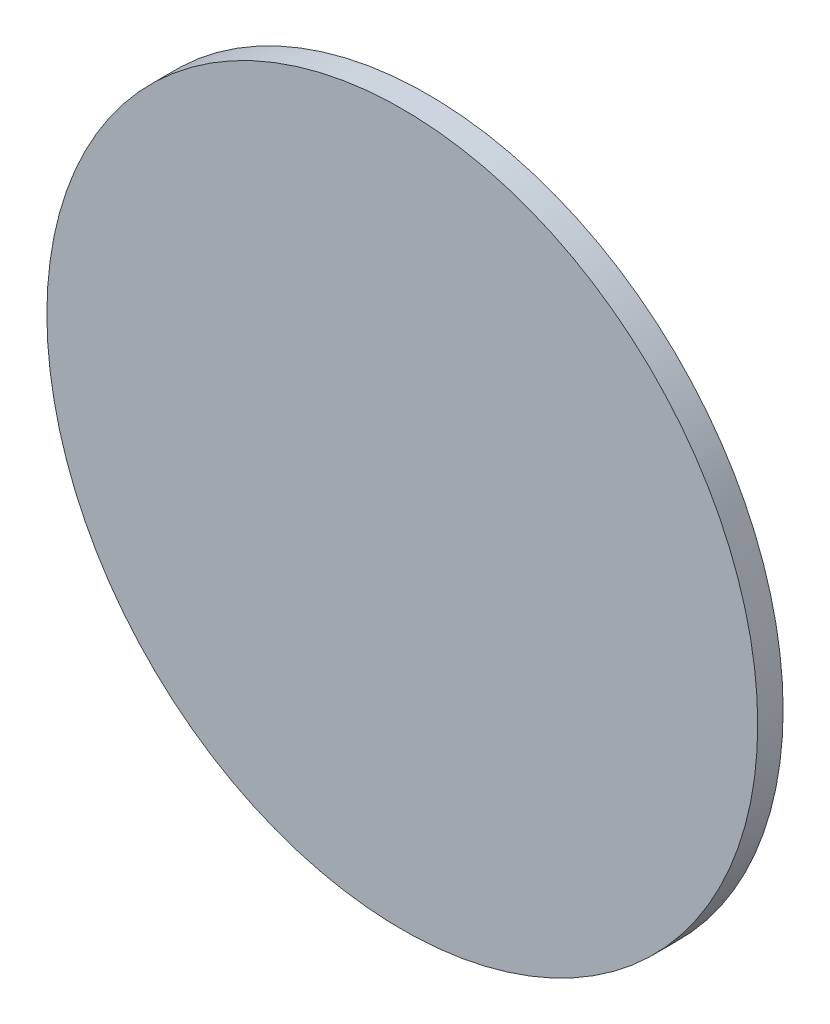
from build123d import *

# Parameters (mm, degrees)
SKETCH1_R      = 44.45
EXTRUDE1_DEPTH = 3.175


with BuildPart() as part:
    # Sketch1 → Extrude1 (new body)
    with BuildSketch(Plane.XY):
        Circle(SKETCH1_R)
    extrude(amount=EXTRUDE1_DEPTH)


solid = part.part
